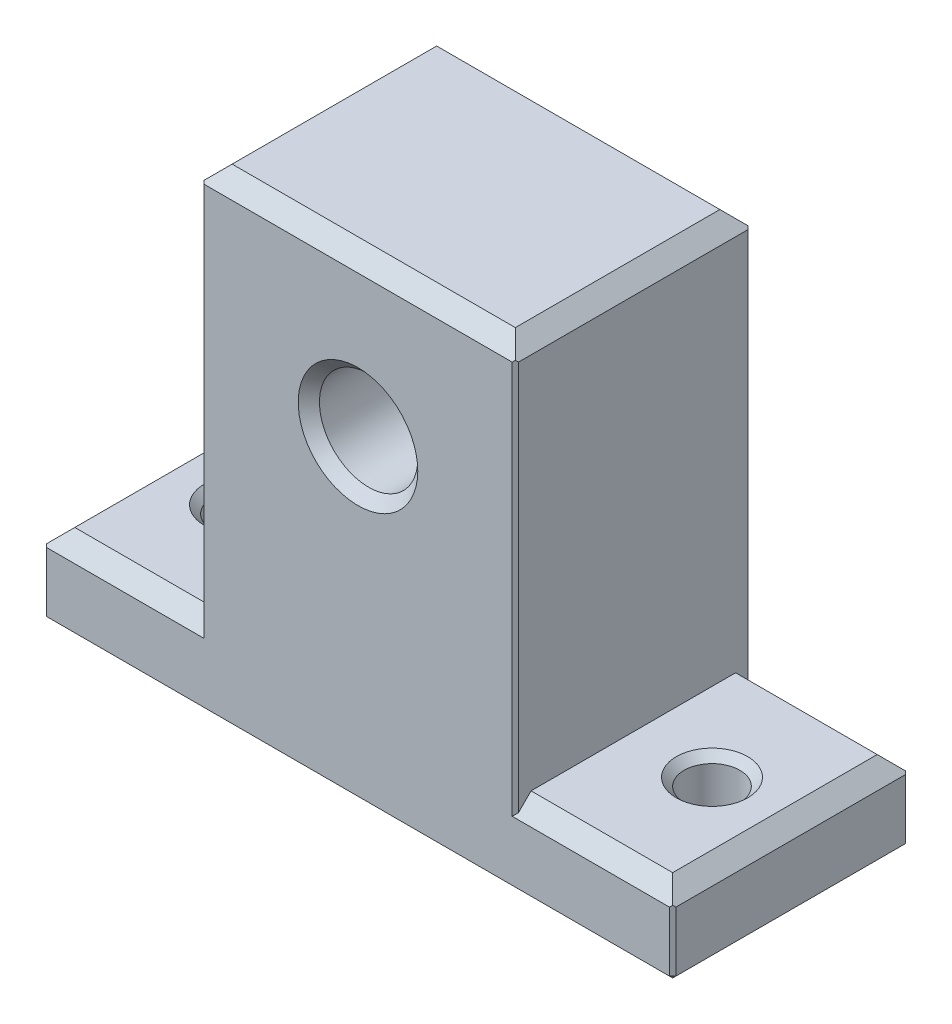
from build123d import *

# Parameters (mm, degrees)
SKETCH1_W                      = 50.8
SKETCH1_H                      = 19.05
BOSS_EXTRUDE1_DEPTH            = 6.35
SKETCH1_3_W                    = 25.4
SKETCH1_3_H                    = 19.05
BOSS_EXTRUDE2_DEPTH            = 38.1
F_8_CLEARANCE_HOLE1_AT_2_COUNT = 2
F_8_CLEARANCE_HOLE1_AT_2_PITCH = 38.1
CHAMFER1_SIZE                  = 1.27
CHAMFER2_SIZE                  = 0.254


with BuildPart() as part:
    # Sketch1 → Boss-Extrude1 (new body)
    with BuildSketch(Plane(origin=(0, 0, 0), x_dir=(1, 0, 0), z_dir=(0, 1, 0))):
        Rectangle(SKETCH1_W, SKETCH1_H)
    extrude(amount=BOSS_EXTRUDE1_DEPTH)

    # Sketch1_3 → Boss-Extrude2 (add)
    with BuildSketch(Plane(origin=(0, 0, 0), x_dir=(1, 0, 0), z_dir=(0, 1, 0))):
        Rectangle(SKETCH1_3_W, SKETCH1_3_H)
    extrude(amount=BOSS_EXTRUDE2_DEPTH)

    # Sketch4 → 3_8-16 Tapped Hole1 (revolve, cut)
    with BuildSketch(Plane(origin=(0, 25.4, 9.525), x_dir=(0, -1, 0), z_dir=(1, 0, 0))):
        Polygon((0, 0), (0, 19.05), (4.826, 19.05), (3.96875, 18.19275), (3.96875, 0.85725), (4.826, 0), align=None)
    revolve(axis=Axis((0, 25.4, 15.875), (0, 0, -1)), mode=Mode.SUBTRACT)

    # Sketch8 → 8 Clearance Hole1 (revolve, cut)
    with BuildSketch(Plane(origin=(-19.05, 6.35, 0), x_dir=(0, 0, 1), z_dir=(1, 0, 0))):
        Polygon((0, 0), (0, 6.35), (2.8829, 6.35), (2.2479, 5.715), (2.2479, 0.635), (2.8829, 0), align=None)
    f_8_clearance_hole1 = revolve(axis=Axis((-19.05, 12.7, 0), (0, -1, 0)), mode=Mode.SUBTRACT)

    # 8 Clearance Hole1 at 2: 8 Clearance Hole1 ×2
    with Locations(*[(i * F_8_CLEARANCE_HOLE1_AT_2_PITCH, 0, 0) for i in range(1, F_8_CLEARANCE_HOLE1_AT_2_COUNT)]):
        add(f_8_clearance_hole1, mode=Mode.SUBTRACT)

    # Chamfer1
    chamfer1_edges = [part.edges().sort_by_distance(p)[0] for p in [
        (-12.7, 38.1, 0),
        (0, 38.1, -9.525),
        (12.7, 38.1, 0),
        (0, 38.1, 9.525),
        (19.05, 6.35, -9.525),
        (25.4, 6.35, 0),
        (19.05, 6.35, 9.525),
        (-19.05, 6.35, -9.525),
        (-19.05, 6.35, 9.525),
        (-25.4, 6.35, 0),
    ]]
    chamfer(chamfer1_edges, length=CHAMFER1_SIZE)

    # Chamfer2
    chamfer2_edges = [part.edges().sort_by_distance(p)[0] for p in [
        (25.4, 2.54, -9.525),
        (25.4, 2.54, 9.525),
        (-25.4, 2.54, -9.525),
        (-25.4, 2.54, 9.525),
        (-25.4, 0, 0),
        (0, 0, -9.525),
        (25.4, 0, 0),
        (0, 0, 9.525),
        (12.7, 20.955, -9.525),
        (12.7, 20.955, 9.525),
        (-12.7, 20.955, 9.525),
        (-12.7, 20.955, -9.525),
    ]]
    chamfer(chamfer2_edges, length=CHAMFER2_SIZE)


solid = part.part
